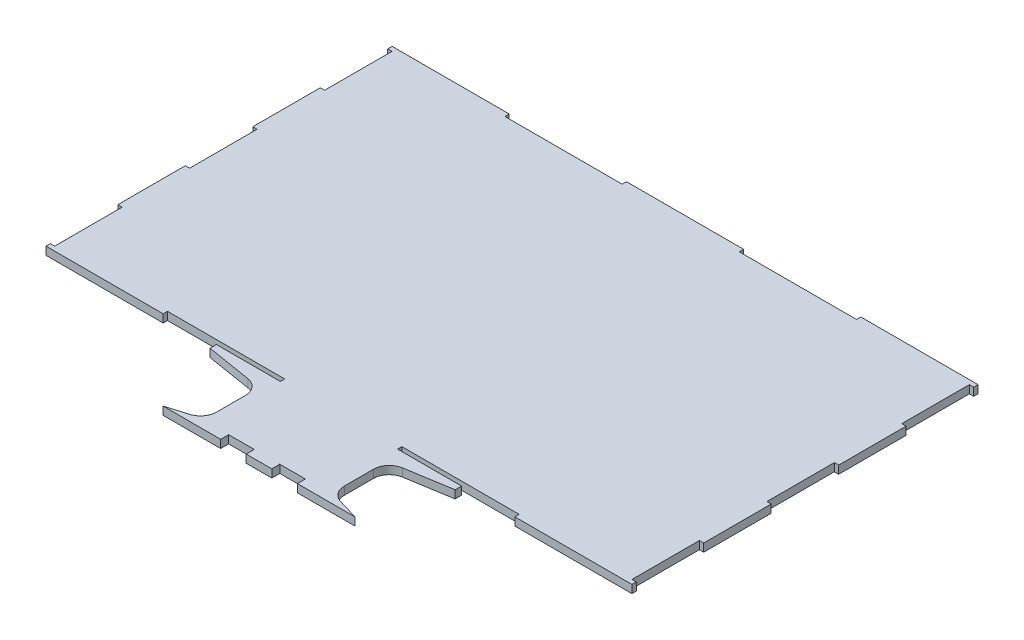
from build123d import *

# Parameters (mm, degrees)
BOSS_EXTRUDE1_DEPTH = 5


with BuildPart() as part:
    # Sketch1 → Boss-Extrude1 (new body)
    with BuildSketch(Plane(origin=(0, 0, 0), x_dir=(1, 0, 0), z_dir=(0, 1, 0))):
        with BuildLine():
            Line((-183.2, 108.2), (-109.92, 108.2))
            Line((-109.92, 108.2), (-109.92, 105.5))
            Line((-109.92, 105.5), (-36.64, 105.5))
            Line((-36.64, 105.5), (-36.64, 108.2))
            Line((-36.64, 108.2), (36.64, 108.2))
            Line((36.64, 108.2), (36.64, 105.5))
            Line((36.64, 105.5), (109.92, 105.5))
            Line((109.92, 105.5), (109.92, 108.2))
            Line((109.92, 108.2), (183.2, 108.2))
            Line((183.2, 108.2), (183.2, 105.5))
            Line((183.2, 105.5), (180.5, 105.5))
            Line((180.5, 105.5), (180.5, 63.3))
            Line((180.5, 63.3), (183.2, 63.3))
            Line((183.2, 63.3), (183.2, 21.1))
            Line((183.2, 21.1), (180.5, 21.1))
            Line((180.5, 21.1), (180.5, -21.1))
            Line((180.5, -21.1), (183.2, -21.1))
            Line((183.2, -21.1), (183.2, -63.3))
            Line((183.2, -63.3), (180.5, -63.3))
            Line((180.5, -63.3), (180.5, -105.5))
            Line((180.5, -105.5), (183.2, -105.5))
            Line((183.2, -105.5), (183.2, -108.2))
            Line((183.2, -108.2), (109.92, -108.2))
            Line((109.92, -108.2), (109.92, -105.5))
            Line((109.92, -105.5), (36.64, -105.5))
            Line((36.64, -105.5), (36.64, -108.2))
            Line((36.64, -108.2), (76.64, -108.2))
            Line((76.64, -108.2), (76.64, -112.2))
            Line((76.64, -112.2), (48.383969685, -116.8270792))
            ThreePointArc((48.383969685, -116.8270792), (42.378966502, -120.22108374), (40, -126.695637657))
            Line((40, -126.695637657), (40, -144.759693491))
            ThreePointArc((40, -144.759693491), (41.977070717, -150.728998787), (47.126521144, -154.337956343))
            Line((47.126521144, -154.337956343), (60, -158.2))
            Line((60, -158.2), (40, -158.2))
            Line((40, -158.2), (24, -158.2))
            Line((24, -158.2), (24, -153.2))
            Line((24, -153.2), (8, -153.2))
            Line((8, -153.2), (8, -158.2))
            Line((8, -158.2), (-8, -158.2))
            Line((-8, -158.2), (-8, -153.2))
            Line((-8, -153.2), (-24, -153.2))
            Line((-24, -153.2), (-24, -158.2))
            Line((-24, -158.2), (-40, -158.2))
            Line((-40, -158.2), (-60, -158.2))
            Line((-60, -158.2), (-47.126521144, -154.337956343))
            ThreePointArc((-47.126521144, -154.337956343), (-41.977070717, -150.728998787), (-40, -144.759693491))
            Line((-40, -144.759693491), (-40, -126.695637657))
            ThreePointArc((-40, -126.695637657), (-42.378966502, -120.22108374), (-48.383969685, -116.8270792))
            Line((-48.383969685, -116.8270792), (-76.64, -112.2))
            Line((-76.64, -112.2), (-76.64, -108.2))
            Line((-76.64, -108.2), (-36.64, -108.2))
            Line((-36.64, -108.2), (-36.64, -105.5))
            Line((-36.64, -105.5), (-109.92, -105.5))
            Line((-109.92, -105.5), (-109.92, -108.2))
            Line((-109.92, -108.2), (-183.2, -108.2))
            Line((-183.2, -108.2), (-183.2, -105.5))
            Line((-183.2, -105.5), (-180.5, -105.5))
            Line((-180.5, -105.5), (-180.5, -63.3))
            Line((-180.5, -63.3), (-183.2, -63.3))
            Line((-183.2, -63.3), (-183.2, -21.1))
            Line((-183.2, -21.1), (-180.5, -21.1))
            Line((-180.5, -21.1), (-180.5, 21.1))
            Line((-180.5, 21.1), (-183.2, 21.1))
            Line((-183.2, 21.1), (-183.2, 63.3))
            Line((-183.2, 63.3), (-180.5, 63.3))
            Line((-180.5, 63.3), (-180.5, 105.5))
            Line((-180.5, 105.5), (-183.2, 105.5))
            Line((-183.2, 105.5), (-183.2, 108.2))
        make_face()
    extrude(amount=BOSS_EXTRUDE1_DEPTH)


solid = part.part
